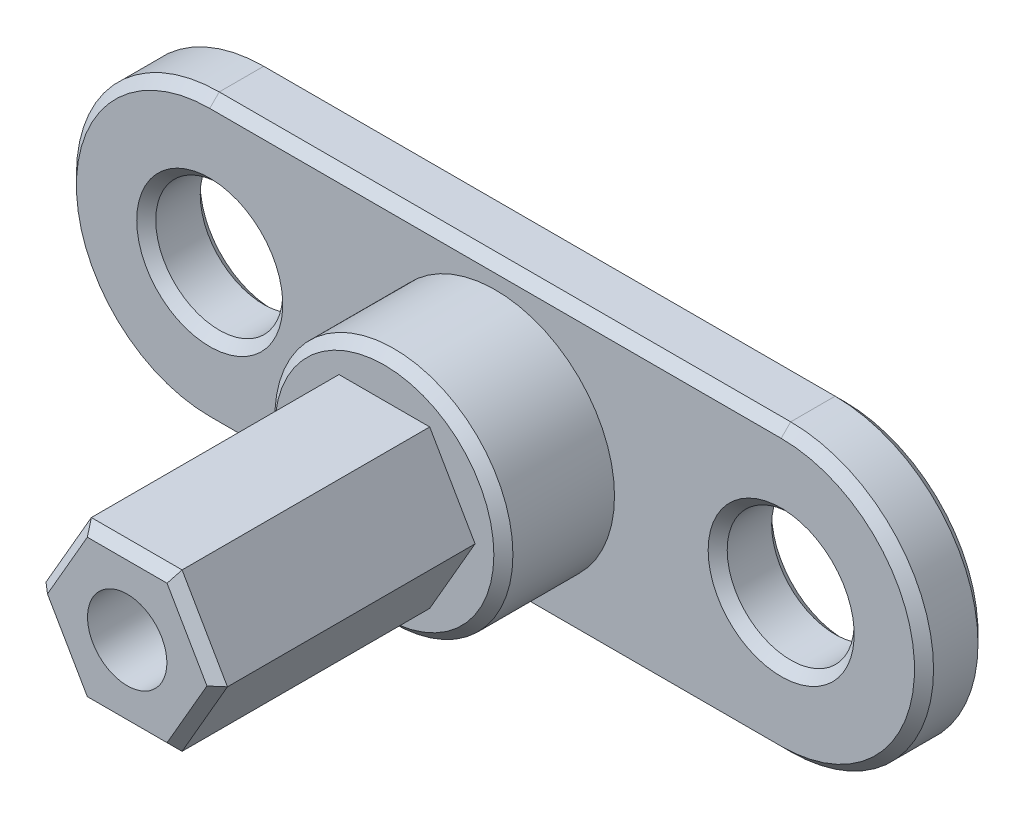
from build123d import *

# Parameters (mm, degrees)
BOSS_EXTRUDE1_DEPTH = 16.2
SKETCH2_R           = 7.5
BOSS_EXTRUDE2_DEPTH = 7
SKETCH3_R           = 4
BOSS_EXTRUDE3_DEPTH = 4
CHAMFER1_SIZE       = 0.6
SKETCH4_R           = 2.5
CUT_EXTRUDE1_DEPTH  = 20


with BuildPart() as part:
    # Sketch1 → Boss-Extrude1 (new body)
    with BuildSketch(Plane.XY):
        Polygon((2.857883832, -4.95), (5.715767665, 0), (2.857883832, 4.95), (-2.857883832, 4.95), (-5.715767665, 0), (-2.857883832, -4.95), align=None)
    extrude(amount=BOSS_EXTRUDE1_DEPTH)

    # Sketch2 → Boss-Extrude2 (add)
    with BuildSketch(Plane.XY):
        Circle(SKETCH2_R)
    extrude(amount=-BOSS_EXTRUDE2_DEPTH)

    # Sketch3 → Boss-Extrude3 (add)
    with BuildSketch(Plane(origin=(0, 0, -7), x_dir=(-1, 0, 0), z_dir=(0, 0, -1))):
        with BuildLine():
            Line((-18, 9), (18, 9))
            ThreePointArc((18, 9), (27, 0), (18, -9))
            Line((18, -9), (-18, -9))
            ThreePointArc((-18, -9), (-27, 0), (-18, 9))
        make_face()
        with Locations((-18, 0)):
            Circle(SKETCH3_R, mode=Mode.SUBTRACT)
        with Locations((18, 0)):
            Circle(SKETCH3_R, mode=Mode.SUBTRACT)
    extrude(amount=BOSS_EXTRUDE3_DEPTH)

    # Chamfer1
    chamfer1_edges = [part.edges().sort_by_distance(p)[0] for p in [
        (4.286825749, 2.475, 16.2),
        (0, 4.95, 16.2),
        (-7.5, 0, 0),
        (-4.286825749, 2.475, 16.2),
        (-4.286825749, -2.475, 16.2),
        (27, 0, -11),
        (0, -9, -11),
        (-27, 0, -11),
        (0, 9, -11),
        (22, 0, -7),
        (-14, 0, -7),
        (27, 0, -7),
        (0, -9, -7),
        (-27, 0, -7),
        (0, 9, -7),
        (22, 0, -11),
        (-14, 0, -11),
        (0, -4.95, 16.2),
        (4.286825749, -2.475, 16.2),
    ]]
    chamfer(chamfer1_edges, length=CHAMFER1_SIZE)

    # Sketch4 → Cut-Extrude1 (cut)
    with BuildSketch(Plane.XY.offset(16.2)):
        Circle(SKETCH4_R)
    extrude(amount=-CUT_EXTRUDE1_DEPTH, mode=Mode.SUBTRACT)


solid = part.part
